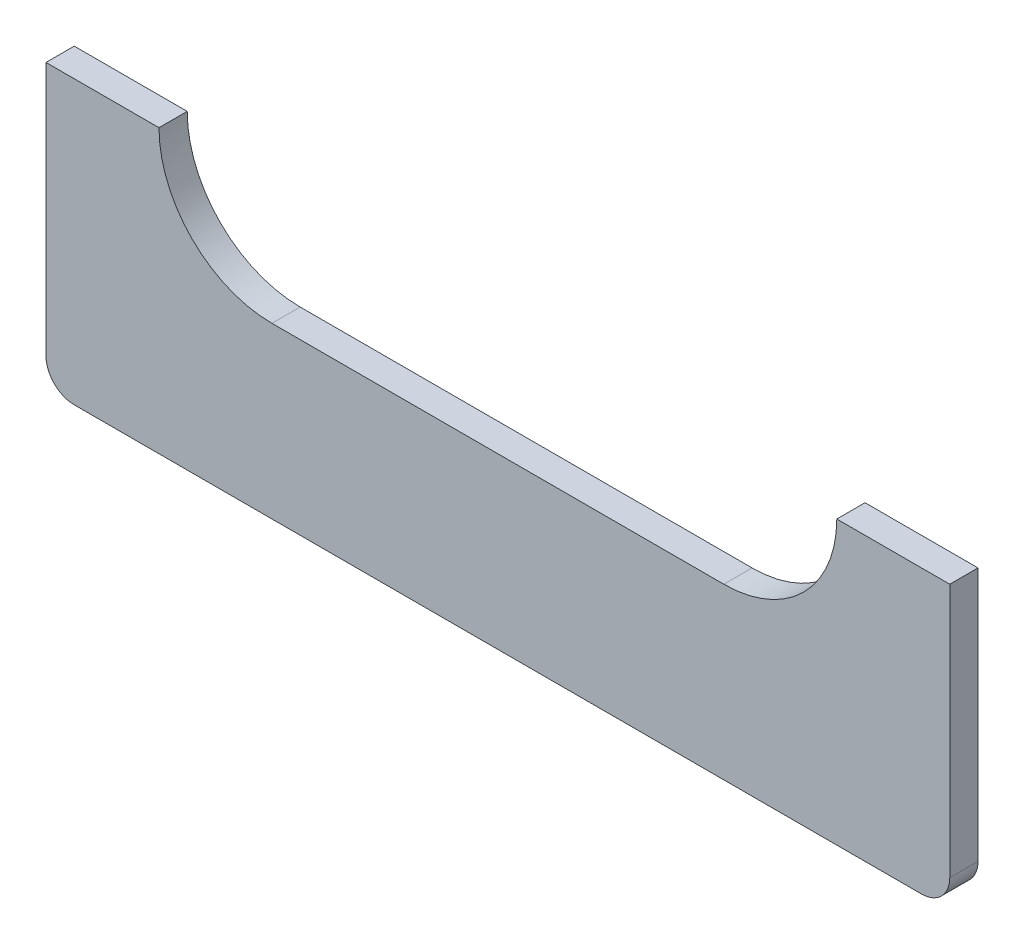
from build123d import *

# Parameters (mm, degrees)
EXTRUDE1_DEPTH = 6.35
FILLET1_R      = 6.35


with BuildPart() as part:
    # Sketch1 → Extrude1 (new body)
    with BuildSketch(Plane.XY):
        with BuildLine():
            Line((-101.6, 0), (-76.2, 0))
            ThreePointArc((-76.2, 0), (-68.760512242, -17.960512242), (-50.8, -25.4))
            Line((-50.8, -25.4), (50.8, -25.4))
            ThreePointArc((50.8, -25.4), (68.760512242, -17.960512242), (76.2, 0))
            Line((76.2, 0), (101.6, 0))
            Line((101.6, 0), (101.6, -63.5))
            Line((101.6, -63.5), (-101.6, -63.5))
            Line((-101.6, -63.5), (-101.6, 0))
        make_face()
    extrude(amount=EXTRUDE1_DEPTH)

    # Fillet1
    fillet1_edges = [part.edges().sort_by_distance(p)[0] for p in [
        (101.6, -63.5, 3.175),
        (-101.6, -63.5, 3.175),
    ]]
    fillet(fillet1_edges, radius=FILLET1_R)


solid = part.part
